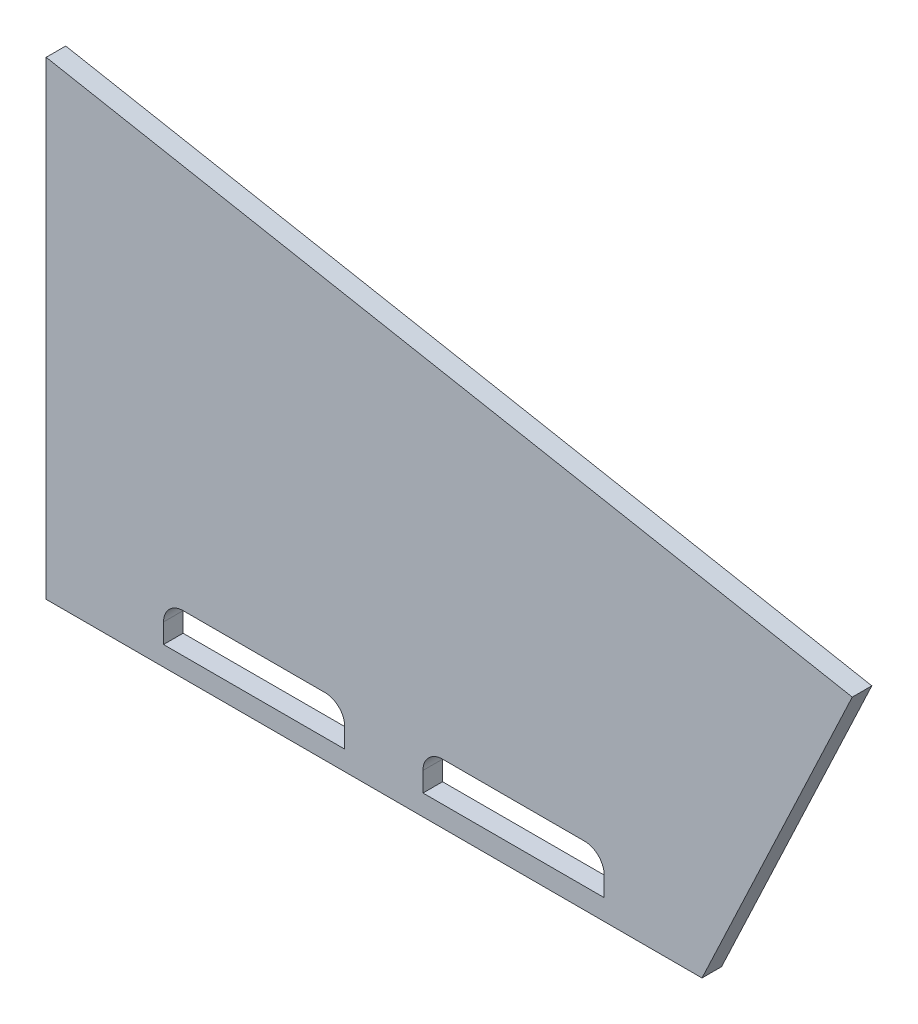
from build123d import *

# Parameters (mm, degrees)
BOSS_EXTRUDE1_DEPTH = 12.7
SKETCH2_W           = 117.66064382
SKETCH2_H           = 25.4
CUT_EXTRUDE1_DEPTH  = 13.7
FILLET1_R           = 12.7


with BuildPart() as part:
    # Sketch1 → Boss-Extrude1 (new body)
    with BuildSketch(Plane.XY):
        Polygon((12.7, 22.225), (12.7, 327.025), (536.089806585, 228.957542458), (438.52128764, 22.225), align=None)
    extrude(amount=-BOSS_EXTRUDE1_DEPTH)

    # Sketch2 → Cut-Extrude1 (cut, through all)
    with BuildSketch(Plane.XY):
        with Locations((147.73032191, 47.625)):
            Rectangle(SKETCH2_W, SKETCH2_H)
        with Locations((316.19096573, 48.355687107)):
            Rectangle(SKETCH2_W, SKETCH2_H)
    extrude(amount=-CUT_EXTRUDE1_DEPTH, mode=Mode.SUBTRACT)

    # Fillet1
    fillet1_edges = [part.edges().sort_by_distance(p)[0] for p in [
        (88.9, 60.325, -6.35),
        (206.56064382, 60.325, -6.35),
        (257.36064382, 61.055687107, -6.35),
        (375.02128764, 61.055687107, -6.35),
    ]]
    fillet(fillet1_edges, radius=FILLET1_R)


solid = part.part
